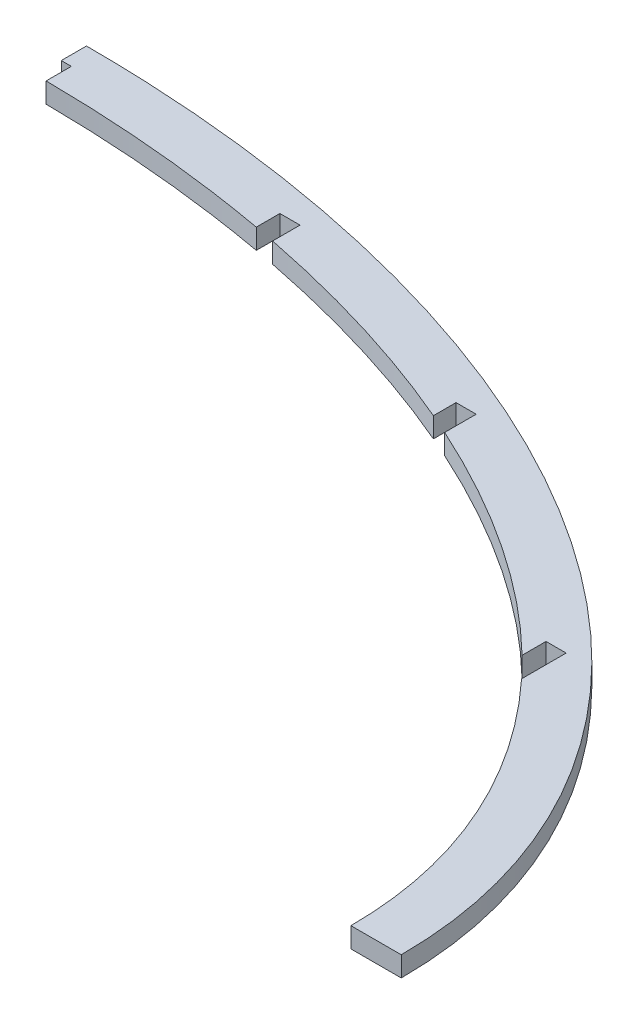
from build123d import *

# Parameters (mm, degrees)
EXTRUDE_1_DEPTH = 16


with BuildPart() as part:
    # Эскиз1 → Бобышка-Вытянуть1 (new body)
    with BuildSketch(Plane(origin=(0, 0, 0), x_dir=(1, 0, 0), z_dir=(0, 1, 0))):
        with BuildLine():
            Line((-1000, 500), (-1000, 480))
            Line((-1000, 480), (-992, 480))
            Line((-992, 480), (-992, 459.970798518))
            add(Edge.make_bspline(
                [(-808, 442.861199089), (-898.256504918, 459.286414541), (-992, 459.970798518)],
                knots=[1.296964435, 1.296964435, 1.296964435, 1.559528483, 1.559528483, 1.559528483], degree=2, weights=[1, 0.991394885, 1]))
            Line((-808, 442.861199089), (-808, 461.62))
            Line((-808, 461.62), (-792, 461.62))
            Line((-792, 461.62), (-792, 439.817678769))
            add(Edge.make_bspline(
                [(-608, 383.533973809), (-693.710948609, 420.305994383), (-792, 439.817678769)],
                knots=[0.985900323, 0.985900323, 0.985900323, 1.273477477, 1.273477477, 1.273477477], degree=2, weights=[1, 0.989680221, 1]))
            Line((-608, 383.533973809), (-608, 401.5))
            Line((-608, 401.5), (-592, 401.5))
            Line((-592, 401.5), (-592, 376.464350057))
            add(Edge.make_bspline(
                [(-408, 253.948691099), (-482.120546549, 326.477961202), (-592, 376.464350057)],
                knots=[0.584835671, 0.584835671, 0.584835671, 0.958622489, 0.958622489, 0.958622489], degree=2, weights=[1, 0.982586203, 1]))
            Line((-408, 253.948691099), (-408, 272.97))
            Line((-408, 272.97), (-392, 272.97))
            Line((-392, 272.97), (-392, 237.551224808))
            add(Edge.make_bspline(
                [(-290, 0), (-290, 127.967655246), (-392, 237.551224808)],
                knots=[0, 0, 0, 0.542660036, 0.542660036, 0.542660036], degree=2, weights=[1, 0.963415286, 1]))
            Line((-290, 0), (-250, 0))
            add(Edge.make_bspline(
                [(-250, 0), (-250, 500), (-1000, 500)],
                knots=[3.141592654, 3.141592654, 3.141592654, 4.71238898, 4.71238898, 4.71238898], degree=2, weights=[1, 0.707106781, 1]))
        make_face()
    extrude(amount=EXTRUDE_1_DEPTH)


solid = part.part
